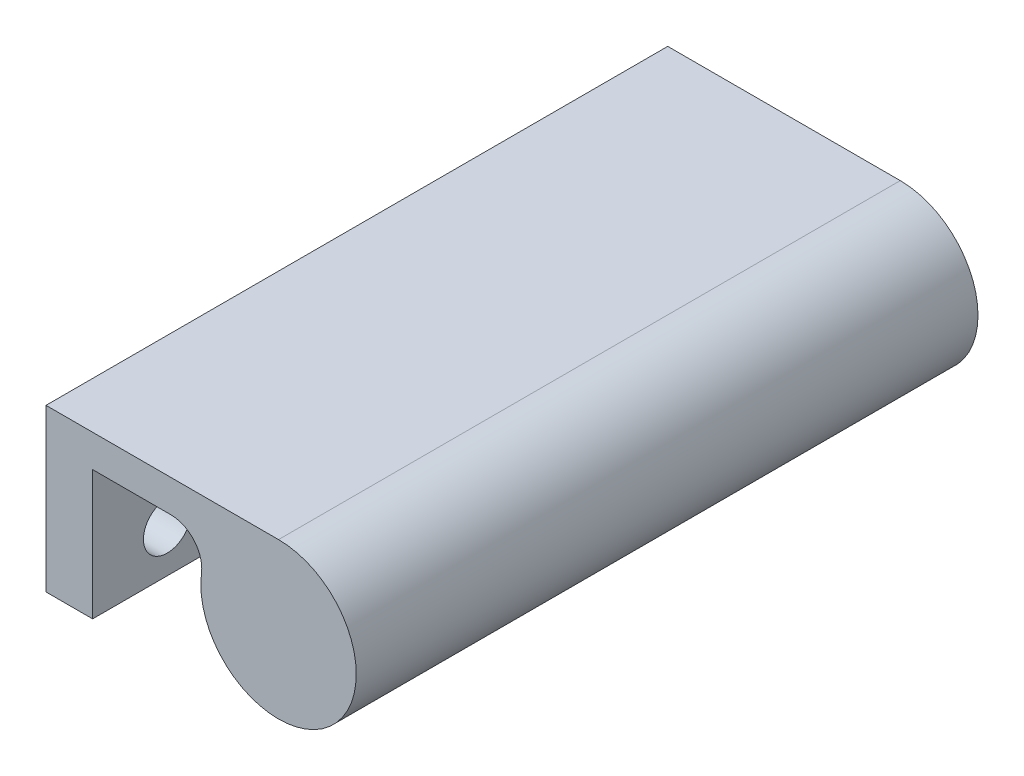
from build123d import *

# Parameters (mm, degrees)
SKETCH1_W        = 16.51
SKETCH1_H        = 63.5
SKETCH1_R        = 2.432856576
EXTRUSION1_DEPTH = 4.7625
SKETCH2_W        = 63.5
SKETCH2_H        = 3.302
EXTRUSION2_DEPTH = 1.016
EXTRUSION3_DEPTH = 63.5


with BuildPart() as part:
    # Sketch1 → Extrusion1 (new body)
    with BuildSketch(Plane.YZ):
        with Locations((8.255, -31.75)):
            Rectangle(SKETCH1_W, SKETCH1_H)
        with Locations((4.445, -55.61076)):
            Circle(SKETCH1_R, mode=Mode.SUBTRACT)
        with Locations((4.445, -47.6123)):
            Circle(SKETCH1_R, mode=Mode.SUBTRACT)
        with Locations((4.445, -39.61384)):
            Circle(SKETCH1_R, mode=Mode.SUBTRACT)
        with Locations((4.445, -31.61538)):
            Circle(SKETCH1_R, mode=Mode.SUBTRACT)
        with Locations((4.445, -23.61692)):
            Circle(SKETCH1_R, mode=Mode.SUBTRACT)
        with Locations((4.445, -15.61846)):
            Circle(SKETCH1_R, mode=Mode.SUBTRACT)
        with Locations((4.445, -7.62)):
            Circle(SKETCH1_R, mode=Mode.SUBTRACT)
    extrude(amount=EXTRUSION1_DEPTH)

    # Sketch2 → Extrusion2 (add)
    with BuildSketch(Plane(origin=(4.7625, 0, 0), x_dir=(0, 0, -1), z_dir=(1, 0, 0))):
        with Locations((31.75, 14.859)):
            Rectangle(SKETCH2_W, SKETCH2_H)
    extrude(amount=EXTRUSION2_DEPTH)

    # Sketch3 → Extrusion3 (add)
    with BuildSketch(Plane.XY):
        with BuildLine():
            Line((23.749, 16.51), (5.7785, 16.51))
            Line((5.7785, 16.51), (5.7785, 13.208))
            Line((5.7785, 13.208), (12.732893791, 13.208))
            ThreePointArc((12.732893791, 13.208), (15.120937671, 12.125336356), (15.880352708, 9.615714286))
            ThreePointArc((15.880352708, 9.615714286), (28.979840891, 2.602390301), (23.749, 16.51))
        make_face()
    extrude(amount=-EXTRUSION3_DEPTH)


solid = part.part
